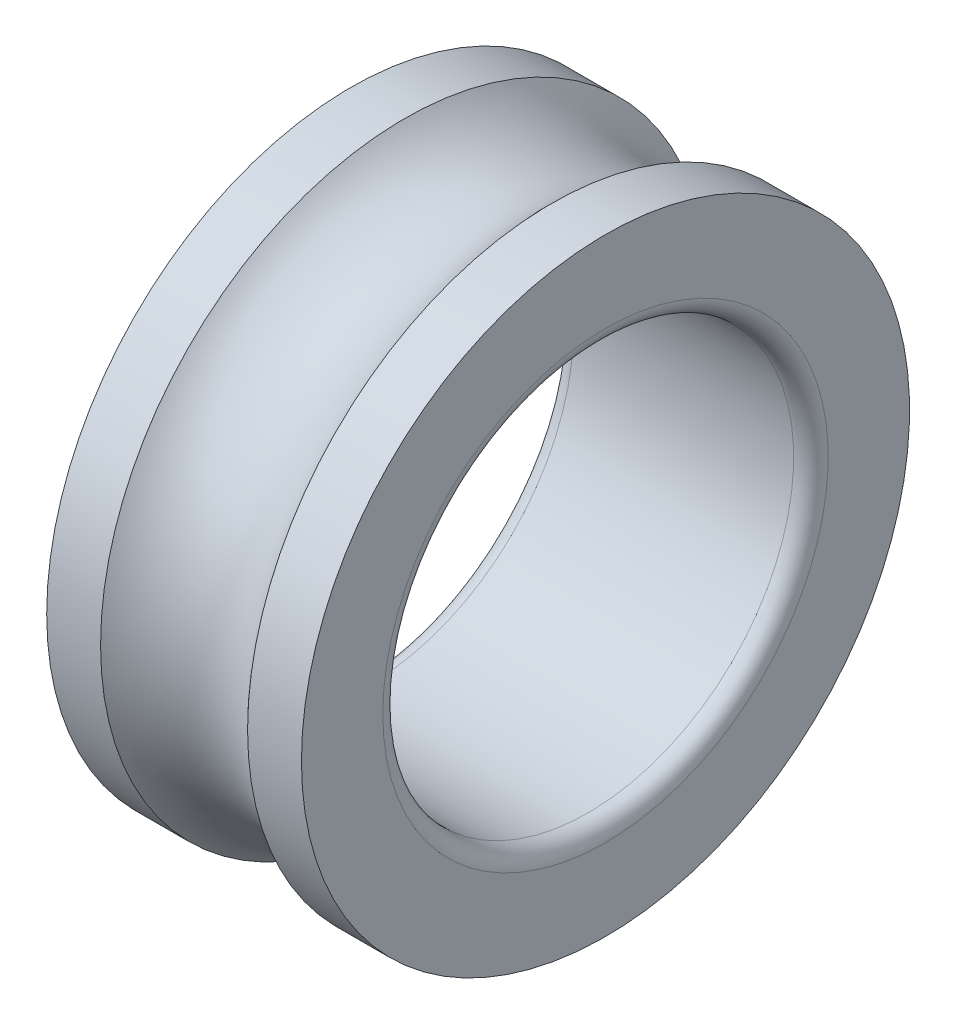
from build123d import *


with BuildPart() as part:
    # Sketch1 → Revolve1 (revolve)
    with BuildSketch(Plane.XY):
        with BuildLine():
            Line((8.94427191, 37), (15.5, 37))
            Line((15.5, 37), (15.5, 27.1))
            ThreePointArc((15.5, 27.1), (14.88492424, 25.61507576), (13.4, 25))
            Line((13.4, 25), (-13.4, 25))
            ThreePointArc((-13.4, 25), (-14.88492424, 25.61507576), (-15.5, 27.1))
            Line((-15.5, 27.1), (-15.5, 37))
            Line((-15.5, 37), (-8.94427191, 37))
            ThreePointArc((-8.94427191, 37), (0, 33), (8.94427191, 37))
        make_face()
    revolve(axis=Axis((-62.704140917, 0, 0), (1, 0, 0)))


solid = part.part
